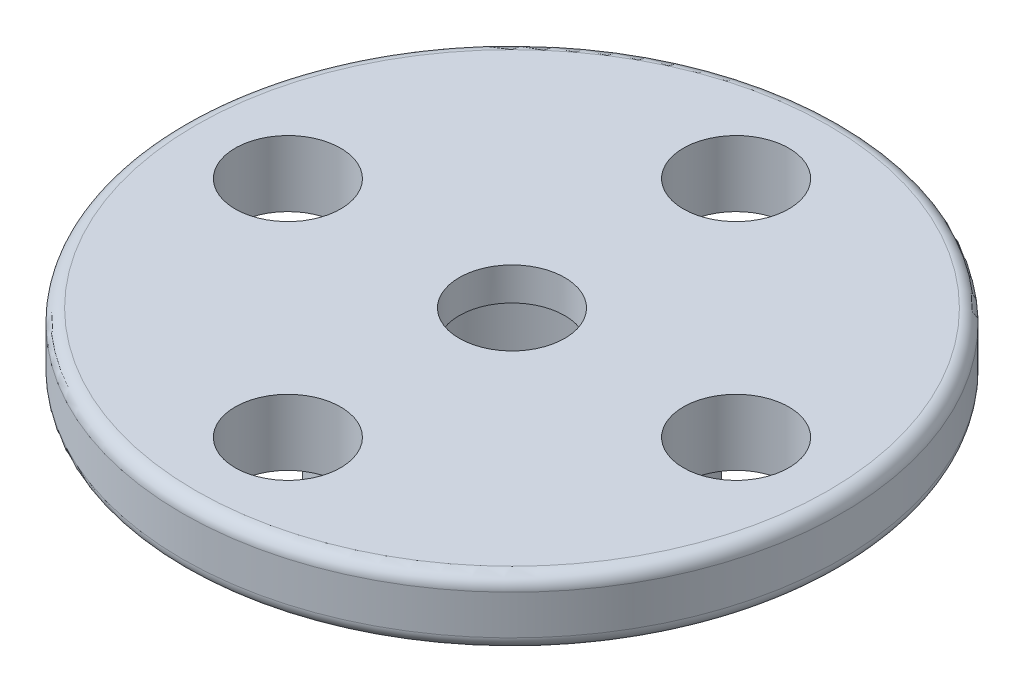
from build123d import *

# Parameters (mm, degrees)
SKETCH1_R           = 10
BOSS_EXTRUDE1_DEPTH = 0.5
SKETCH2_R           = 10
BOSS_EXTRUDE2_DEPTH = 0.5
SKETCH3_R           = 10
BOSS_EXTRUDE3_DEPTH = 1
SKETCH5_R           = 1.6
CUT_EXTRUDE2_DEPTH  = 3
SKETCH8_R           = 1.6
CUT_EXTRUDE4_DEPTH  = 10
FILLET1_R           = 0.4
SKETCH9_R           = 4.5
SKETCH9_R_2         = 3.5
BOSS_EXTRUDE4_DEPTH = 3
SKETCH10_R          = 3.5
CUT_EXTRUDE5_DEPTH  = 1
FILLET3_R           = 1.2


with BuildPart() as part:
    # Sketch1 → Boss-Extrude1 (new body)
    with BuildSketch(Plane(origin=(0, 0, 0), x_dir=(1, 0, 0), z_dir=(0, 1, 0))):
        Circle(SKETCH1_R)
    extrude(amount=BOSS_EXTRUDE1_DEPTH)

    # Sketch2 → Boss-Extrude2 (add)
    with BuildSketch(Plane(origin=(0, 0.5, 0), x_dir=(1, 0, 0), z_dir=(0, 1, 0))):
        Circle(SKETCH2_R)
    extrude(amount=BOSS_EXTRUDE2_DEPTH)

    # Sketch3 → Boss-Extrude3 (add)
    with BuildSketch(Plane(origin=(0, 1, 0), x_dir=(1, 0, 0), z_dir=(0, 1, 0))):
        Circle(SKETCH3_R)
    extrude(amount=BOSS_EXTRUDE3_DEPTH)

    # Sketch5 → Cut-Extrude2 (cut, through all)
    with BuildSketch(Plane(origin=(0, 2, 0), x_dir=(1, 0, 0), z_dir=(0, 1, 0))):
        Circle(SKETCH5_R)
    extrude(amount=-CUT_EXTRUDE2_DEPTH, mode=Mode.SUBTRACT)

    # Sketch8 → Cut-Extrude4 (cut)
    with BuildSketch(Plane(origin=(0, 2, 0), x_dir=(1, 0, 0), z_dir=(0, 1, 0))):
        with Locations((-6.8, 0)):
            Circle(SKETCH8_R)
        with Locations((6.8, 0)):
            Circle(SKETCH8_R)
        with Locations((0, 6.8)):
            Circle(SKETCH8_R)
        with Locations((0, -6.8)):
            Circle(SKETCH8_R)
    extrude(amount=-CUT_EXTRUDE4_DEPTH, mode=Mode.SUBTRACT)

    # Fillet1
    fillet1_edges = [part.edges().sort_by_distance(p)[0] for p in [
        (-10, 0, 0),
        (-10, 2, 0),
    ]]
    fillet(fillet1_edges, radius=FILLET1_R)

    # Sketch9 → Boss-Extrude4 (add)
    with BuildSketch(Plane.XZ):
        Circle(SKETCH9_R)
        Circle(SKETCH9_R_2, mode=Mode.SUBTRACT)
    extrude(amount=BOSS_EXTRUDE4_DEPTH)

    # Sketch10 → Cut-Extrude5 (cut)
    with BuildSketch(Plane.XZ):
        Circle(SKETCH10_R)
    extrude(amount=-CUT_EXTRUDE5_DEPTH, mode=Mode.SUBTRACT)

    # Fillet3
    fillet3_edges = [part.edges().sort_by_distance(p)[0] for p in [
        (-3.5, 1, 0),
    ]]
    fillet(fillet3_edges, radius=FILLET3_R)


solid = part.part
